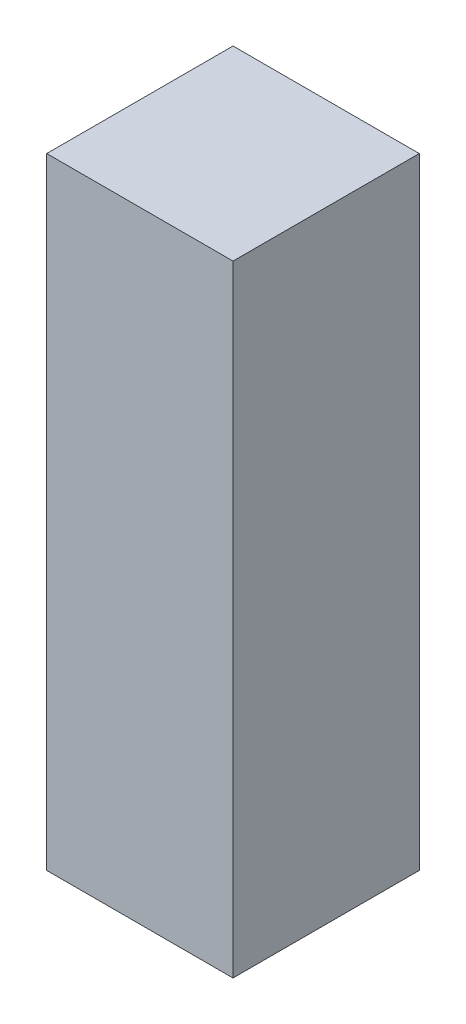
from build123d import *

# Parameters (mm, degrees)
SKETCH1_W           = 3
SKETCH1_H           = 3
BOSS_EXTRUDE1_DEPTH = 10


with BuildPart() as part:
    # Sketch1 → Boss-Extrude1 (new body)
    with BuildSketch(Plane(origin=(0, 0, 0), x_dir=(1, 0, 0), z_dir=(0, 1, 0))):
        with Locations((1.5, 1.5)):
            Rectangle(SKETCH1_W, SKETCH1_H)
    extrude(amount=BOSS_EXTRUDE1_DEPTH)


solid = part.part
